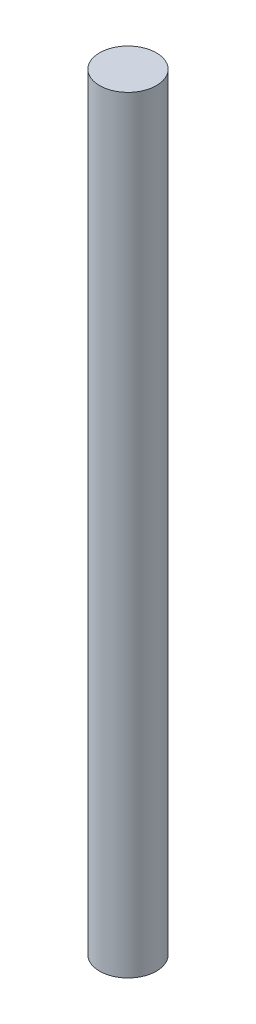
from build123d import *

# Parameters (mm, degrees)
ESBO_O1_R                = 5
RESSALTO_EXTRUS_O1_DEPTH = 135


with BuildPart() as part:
    # Esboço1 → Ressalto-extrusão1 (new body)
    with BuildSketch(Plane(origin=(0, 0, 0), x_dir=(1, 0, 0), z_dir=(0, 1, 0))):
        Circle(ESBO_O1_R)
    extrude(amount=RESSALTO_EXTRUS_O1_DEPTH)


solid = part.part
